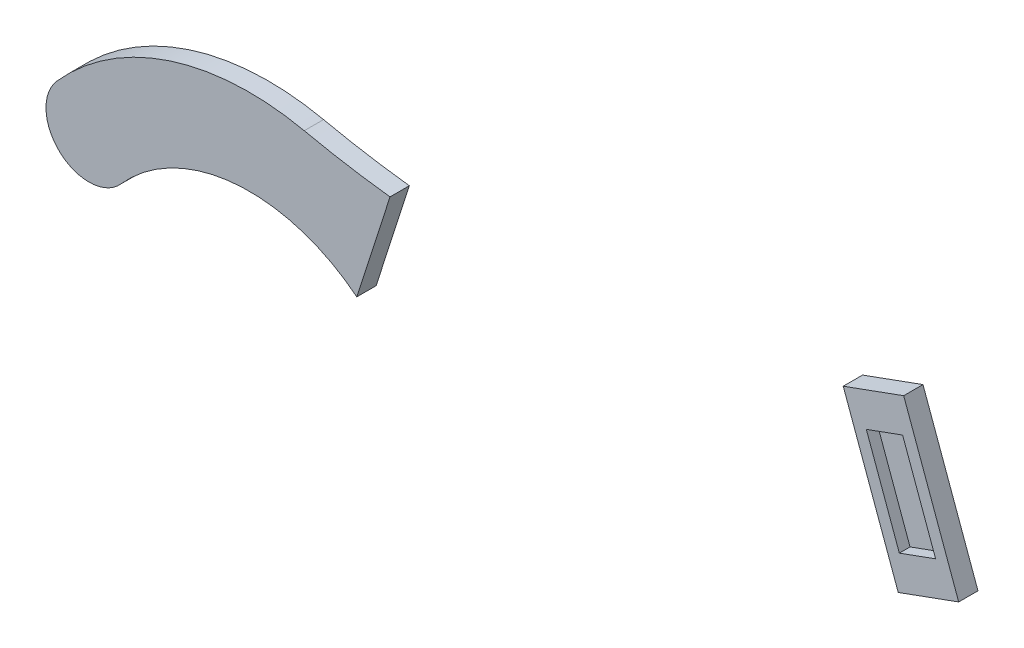
from build123d import *

# Parameters (mm, degrees)
BOSS_EXTRUDE1_DEPTH = 18
SKETCH2_W           = 200
SKETCH2_H           = 97
CUT_EXTRUDE1_DEPTH  = 19
CUT_EXTRUDE2_DEPTH  = 19
CUT_EXTRUDE3_DEPTH  = 10


with BuildPart() as part:
    # Sketch1 → Boss-Extrude1 (new body)
    with BuildSketch(Plane.XY):
        with BuildLine():
            Line((0, 0), (51.303021499, -140.953893118))
            Line((51.303021499, -140.953893118), (-5.078535748, -161.475101717))
            ThreePointArc((-5.078535748, -161.475101717), (-59.282744504, -247.94612641), (-59.866905015, -350))
            Line((-59.866905015, -350), (-458.18031046, -350))
            ThreePointArc((-458.18031046, -350), (-530.476755656, -161.257646224), (-729.936822659, -193.909350133))
            ThreePointArc((-729.936822659, -193.909350133), (-786.401902791, -197.329105332), (-789.82165799, -140.864025199))
            ThreePointArc((-789.82165799, -140.864025199), (-684.665051265, -71.855170989), (-559.047216388, -65.507458149))
            ThreePointArc((-559.047216388, -65.507458149), (-324.287619955, -82.844559906), (-93.969262079, -34.202014333))
            Line((-93.969262079, -34.202014333), (0, 0))
        make_face()
    extrude(amount=BOSS_EXTRUDE1_DEPTH)

    # Sketch2 → Cut-Extrude1 (cut, through all)
    with BuildSketch(Plane.XY.offset(18)):
        with Locations((-187.508312236, -266.5)):
            Rectangle(SKETCH2_W, SKETCH2_H)
        with BuildLine():
            Line((-322.508312236, -315), (-432.508312236, -315))
            Line((-432.508312236, -315), (-432.508312236, -255))
            ThreePointArc((-432.508312236, -255), (-377.508312236, -200), (-322.508312236, -255))
            Line((-322.508312236, -255), (-322.508312236, -315))
        make_face()
    extrude(amount=-CUT_EXTRUDE1_DEPTH, mode=Mode.SUBTRACT)

    # Sketch4 → Cut-Extrude2 (cut, through all)
    with BuildSketch(Plane.XY.offset(18)):
        Polygon((-5.078535748, -161.475101717), (-84.826670929, 57.631098935), (-457.092499605, -10.764738535), (-587.040553494, -414.486123748), (5.988618542, -394.516024731), align=None)
    extrude(amount=-CUT_EXTRUDE2_DEPTH, mode=Mode.SUBTRACT)

    # Sketch3 → Cut-Extrude3 (cut)
    with BuildSketch(Plane.XY.offset(18)):
        Polygon((-1.01570715, -32.295020343), (29.76610575, -116.867356214), (-4.062828599, -129.180081374), (-34.844641498, -44.607745503), align=None)
    extrude(amount=-CUT_EXTRUDE3_DEPTH, mode=Mode.SUBTRACT)


solid = part.part
